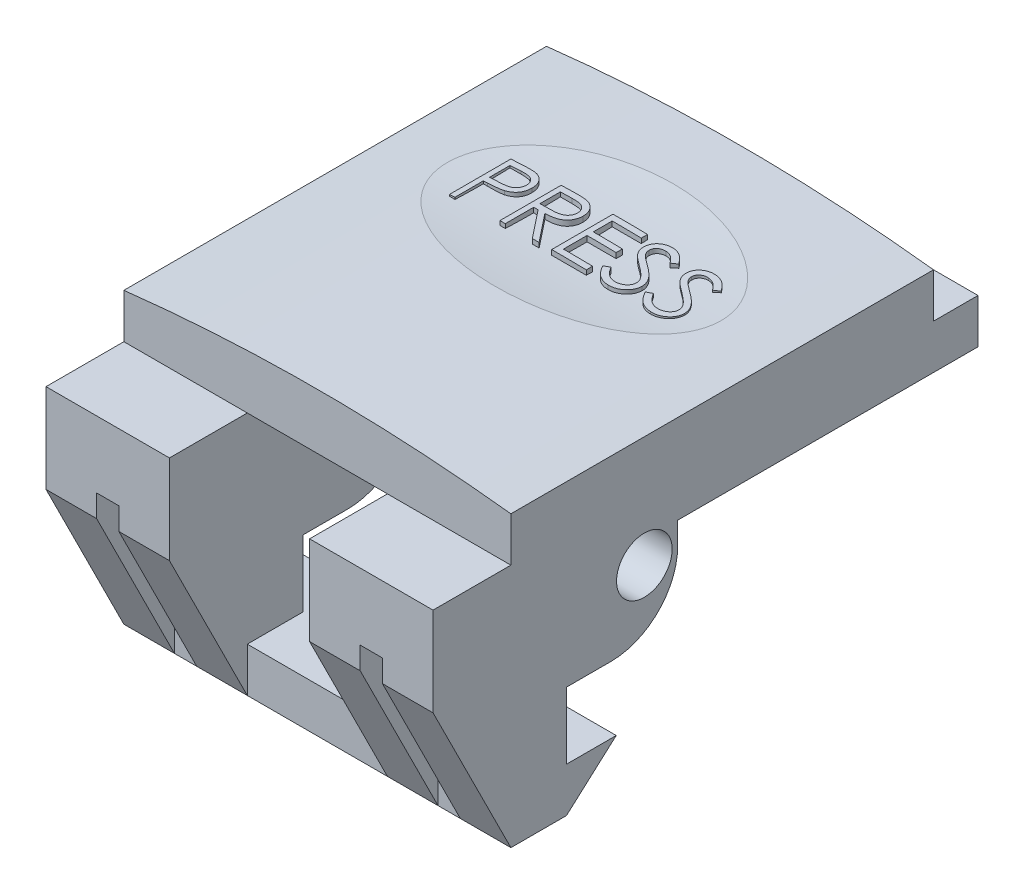
from build123d import *

# Parameters (mm, degrees)
SKETCH1_W                             = 22.098
SKETCH1_H                             = 24.13
BUTTON_MAIN_DEPTH                     = 2.54
LATCH_HOOK_REACH                      = 18.556
LATCH_HOOK_DIRECTION_2_REACH          = 18.556
SKETCH3_W                             = 8.001
SKETCH3_H                             = 11.43
CENTER_CUTOUT_DEPTH                   = 26.831000774
CENTER_CUTOUT_DEPTH_BACK              = 26.831000774
BACKSIDE_START                        = -4.445
SKETCH4_W                             = 1.27
SKETCH4_H                             = 10.16
SKETCH4_W_2                           = 8.001
SKETCH4_H_2                           = 2.54
BACKSIDE_CUTOUT_DEPTH                 = 4.445
SKETCH5_R                             = 1.5875
LATCH_AND_SPRING_PIN_HOLE_DEPTH       = 26.831000774
LATCH_AND_SPRING_PIN_HOLE_DEPTH_BACK  = 26.831000774
ROUNDED_TOP_SURFACE_REACH             = 27.831
ROUNDED_TOP_SURFACE_DIRECTION_2_REACH = 27.831
PRESS_LABEL_CUTOUT_DEPTH              = 8.255
PRESS_LABEL_REACH                     = 27.831
PRESS_LABEL_END_RADIUS                = 96.4438


with BuildPart() as part:
    # Sketch1 → button main (new body)
    with BuildSketch(Plane(origin=(0, 0, 0), x_dir=(1, 0, 0), z_dir=(0, 1, 0))):
        Rectangle(SKETCH1_W, SKETCH1_H)
    extrude(amount=-BUTTON_MAIN_DEPTH)

    # latch hook: up to this face of the body (flat: up to its plane)
    latch_hook_end = Plane(part.part.faces().sort_by_distance((11.049, -1.27, 0))[0])
    # Sketch2 → latch hook (add, up to the picked face)
    with BuildSketch(Plane(origin=(0, 0, 0), x_dir=(0, 0, -1), z_dir=(1, 0, 0)), mode=Mode.PRIVATE) as latch_hook_sk1:
        with BuildLine():
            Line((-12.065, -2.54), (14.605, -2.54))
            Line((14.605, -2.54), (14.605, -5.08))
            Line((14.605, -5.08), (-2.54, -5.08))
            Line((-2.54, -5.08), (-2.54, -6.35))
            ThreePointArc((-2.54, -6.35), (-3.655923164, -9.044076836), (-6.35, -10.16))
            Line((-6.35, -10.16), (-8.89, -10.16))
            Line((-8.89, -10.16), (-8.89, -13.97))
            Line((-8.89, -13.97), (-6.050193669, -13.97))
            Line((-6.050193669, -13.97), (-8.89, -16.51))
            Line((-8.89, -16.51), (-12.065, -16.51))
            Line((-12.065, -16.51), (-16.51, -7.62))
            Line((-16.51, -7.62), (-16.51, -2.54))
            Line((-16.51, -2.54), (-12.065, -2.54))
        make_face()
    latch_hook_tool1 = split(extrude(latch_hook_sk1.sketch, amount=LATCH_HOOK_REACH, mode=Mode.PRIVATE), bisect_by=latch_hook_end, keep=Keep.BOTH, mode=Mode.PRIVATE)
    add(latch_hook_tool1.solids().sort_by(Axis((0, -6.944553, 6.068075), (1, 0, 0)))[0])

    # latch hook direction 2: up to this face of the body (flat: up to its plane)
    latch_hook_direction_2_end = Plane(part.part.faces().sort_by_distance((-11.049, -1.27, 0))[0])
    # Sketch2 → latch hook direction 2 (add, up to the picked face)
    with BuildSketch(Plane(origin=(0, 0, 0), x_dir=(0, 0, -1), z_dir=(1, 0, 0)), mode=Mode.PRIVATE) as latch_hook_direction_2_sk1:
        with BuildLine():
            Line((-12.065, -2.54), (14.605, -2.54))
            Line((14.605, -2.54), (14.605, -5.08))
            Line((14.605, -5.08), (-2.54, -5.08))
            Line((-2.54, -5.08), (-2.54, -6.35))
            ThreePointArc((-2.54, -6.35), (-3.655923164, -9.044076836), (-6.35, -10.16))
            Line((-6.35, -10.16), (-8.89, -10.16))
            Line((-8.89, -10.16), (-8.89, -13.97))
            Line((-8.89, -13.97), (-6.050193669, -13.97))
            Line((-6.050193669, -13.97), (-8.89, -16.51))
            Line((-8.89, -16.51), (-12.065, -16.51))
            Line((-12.065, -16.51), (-16.51, -7.62))
            Line((-16.51, -7.62), (-16.51, -2.54))
            Line((-16.51, -2.54), (-12.065, -2.54))
        make_face()
    latch_hook_direction_2_tool1 = split(extrude(latch_hook_direction_2_sk1.sketch, amount=-LATCH_HOOK_DIRECTION_2_REACH, mode=Mode.PRIVATE), bisect_by=latch_hook_direction_2_end, keep=Keep.BOTH, mode=Mode.PRIVATE)
    add(latch_hook_direction_2_tool1.solids().sort_by(Axis((0, -6.944553, 6.068075), (-1, 0, 0)))[0])

    # Sketch3 → center cutout (cut, two sides)
    with BuildSketch(Plane.XY) as center_cutout_sk:
        with Locations((0, -8.255)):
            Rectangle(SKETCH3_W, SKETCH3_H)
    extrude(amount=CENTER_CUTOUT_DEPTH, mode=Mode.SUBTRACT)
    extrude(center_cutout_sk.sketch, amount=-CENTER_CUTOUT_DEPTH_BACK, mode=Mode.SUBTRACT)

    # Sketch4 → backside cutout (cut)
    with BuildSketch(Plane.XY.offset(16.51).offset(BACKSIDE_START)):
        with Locations((7.52475, -11.43)):
            Rectangle(SKETCH4_W, SKETCH4_H)
        with Locations((-7.52475, -11.43)):
            Rectangle(SKETCH4_W, SKETCH4_H)
        with Locations((0, -15.24)):
            Rectangle(SKETCH4_W_2, SKETCH4_H_2)
    extrude(amount=BACKSIDE_CUTOUT_DEPTH, mode=Mode.SUBTRACT)

    # Sketch5 → latch and spring pin hole (cut, two sides)
    with BuildSketch(Plane(origin=(0, 0, 0), x_dir=(0, 0, -1), z_dir=(1, 0, 0))) as latch_and_spring_pin_hole_sk:
        with Locations((-4.445, -6.35)):
            Circle(SKETCH5_R)
    extrude(amount=LATCH_AND_SPRING_PIN_HOLE_DEPTH, mode=Mode.SUBTRACT)
    extrude(latch_and_spring_pin_hole_sk.sketch, amount=-LATCH_AND_SPRING_PIN_HOLE_DEPTH_BACK, mode=Mode.SUBTRACT)

    # rounded top surface: up to this face of the body (flat: up to its plane)
    rounded_top_surface_end = Plane(part.part.faces().sort_by_distance((0, -1.27, 12.065))[0])
    # Sketch8 → rounded top surface (add, up to the picked face)
    with BuildSketch(Plane.XY, mode=Mode.PRIVATE) as rounded_top_surface_sk1:
        with BuildLine():
            Line((-11.049, 0), (11.049, 0))
            ThreePointArc((11.049, 0), (0, 0.635), (-11.049, 0))
        make_face()
    rounded_top_surface_tool1 = split(extrude(rounded_top_surface_sk1.sketch, amount=ROUNDED_TOP_SURFACE_REACH, mode=Mode.PRIVATE), bisect_by=rounded_top_surface_end, keep=Keep.BOTH, mode=Mode.PRIVATE)
    add(rounded_top_surface_tool1.solids().sort_by(Axis((0, 0.254072, 0), (0, 0, 1)))[0])

    # rounded top surface direction 2: up to this face of the body (flat: up to its plane)
    rounded_top_surface_direction_2_end = Plane(part.part.faces().sort_by_distance((0, -1.27, -12.065))[0])
    # Sketch8 → rounded top surface direction 2 (add, up to the picked face)
    with BuildSketch(Plane.XY, mode=Mode.PRIVATE) as rounded_top_surface_direction_2_sk1:
        with BuildLine():
            Line((-11.049, 0), (11.049, 0))
            ThreePointArc((11.049, 0), (0, 0.635), (-11.049, 0))
        make_face()
    rounded_top_surface_direction_2_tool1 = split(extrude(rounded_top_surface_direction_2_sk1.sketch, amount=-ROUNDED_TOP_SURFACE_DIRECTION_2_REACH, mode=Mode.PRIVATE), bisect_by=rounded_top_surface_direction_2_end, keep=Keep.BOTH, mode=Mode.PRIVATE)
    add(rounded_top_surface_direction_2_tool1.solids().sort_by(Axis((0, 0.254072, 0), (0, 0, -1)))[0])

    # Sketch11 → PRESS label cutout (cut, symmetric)
    with BuildSketch(Plane(origin=(0, 0, 0), x_dir=(0, 0, -1), z_dir=(1, 0, 0))):
        with BuildLine():
            Line((-1.905, 0.635), (8.255, 0.635))
            ThreePointArc((8.255, 0.635), (3.175, 0.3175), (-1.905, 0.635))
        make_face()
    extrude(amount=PRESS_LABEL_CUTOUT_DEPTH, both=True, mode=Mode.SUBTRACT)

    # PRESS label: up to this cylinder (the profile starts inside it)
    press_label_end = Plane(origin=(0, -95.8088, -4.1117645), z_dir=(0, 0, -1)) * Cylinder(PRESS_LABEL_END_RADIUS, 251.304077, mode=Mode.PRIVATE)
    # Sketch12 → PRESS label (add, up to the surface)
    with BuildSketch(Plane(origin=(0, 0, 0), x_dir=(1, 0, 0), z_dir=(0, 1, 0)), mode=Mode.PRIVATE) as press_label_sk1:
        with BuildLine():
            Line((-6.050444649, 5.030099377), (-5.364046412, 5.030099377))
            add(Edge.make_bspline(
                [(-5.364046412, 5.030099377), (-5.316835506, 5.030047481), (-5.226377313, 5.029948046), (-5.096662257, 5.0269333), (-4.978852526, 5.022906608), (-4.873202145, 5.017324715), (-4.779386047, 5.010728124), (-4.697828747, 5.001476085), (-4.627889191, 4.991815789), (-4.585982741, 4.981994383), (-4.566870931, 4.977515243)],
                knots=[0, 0, 0, 0, 1.415646017, 2.712440637, 3.8905458, 4.950247383, 5.884950622, 6.709939814, 7.411656543, 8, 8, 8, 8], degree=3))
            add(Edge.make_bspline(
                [(-4.566870931, 4.977515243), (-4.542677397, 4.970893293), (-4.49486042, 4.957805431), (-4.425959377, 4.931591708), (-4.360405531, 4.900509543), (-4.297973973, 4.865085603), (-4.23943189, 4.823800039), (-4.183905849, 4.778326421), (-4.131885869, 4.727614852), (-4.083664477, 4.672234112), (-4.039379679, 4.613113903), (-4.001249996, 4.549371673), (-3.969322769, 4.482080369), (-3.941939498, 4.411286798), (-3.922231044, 4.336396475), (-3.907384144, 4.257929762), (-3.897960516, 4.175895072), (-3.897057954, 4.119835204), (-3.896598495, 4.091297294)],
                knots=[0, 0, 0, 0, 0.999701418, 1.975846123, 2.934577507, 3.890451536, 4.834027766, 5.787354733, 6.749476667, 7.726910423, 8.712836071, 9.690891519, 10.682875813, 11.679750201, 12.712814741, 13.765529915, 14.8625177, 16, 16, 16, 16], degree=3))
            add(Edge.make_bspline(
                [(-3.896598495, 4.091297294), (-3.89701992, 4.062519517), (-3.897844466, 4.006213853), (-3.907740751, 3.923841065), (-3.921070943, 3.845122675), (-3.941567995, 3.770233225), (-3.968413668, 3.699617454), (-3.999905721, 3.632196222), (-4.037889251, 3.56911655), (-4.081534081, 3.510149433), (-4.130085676, 3.45523952), (-4.183338614, 3.404784726), (-4.241077906, 3.359080387), (-4.303120054, 3.318024044), (-4.370069903, 3.282567764), (-4.440912057, 3.250810459), (-4.516262273, 3.224139399), (-4.568404787, 3.210109337), (-4.594915803, 3.20297598)],
                knots=[0, 0, 0, 0, 1.121902311, 2.195077645, 3.232258892, 4.234102512, 5.217864754, 6.176164875, 7.132989551, 8.084763148, 9.034132444, 9.988522005, 10.94243251, 11.903244335, 12.886203696, 13.894208494, 14.929344452, 16, 16, 16, 16], degree=3))
            add(Edge.make_bspline(
                [(-4.594915803, 3.20297598), (-4.616843137, 3.198312999), (-4.664898164, 3.188093805), (-4.744040886, 3.176685348), (-4.836186272, 3.166947747), (-4.941208552, 3.15964661), (-5.059013457, 3.153396241), (-5.189664714, 3.148428147), (-5.333418792, 3.145698293), (-5.433690036, 3.145557501), (-5.486041604, 3.145483993)],
                knots=[0, 0, 0, 0, 0.601384939, 1.31797006, 2.144135048, 3.087295005, 4.142315834, 5.309527816, 6.595305764, 8, 8, 8, 8], degree=3))
            Line((-5.486041604, 3.145483993), (-5.736342085, 3.145483993))
            Line((-5.736342085, 3.145483993), (-5.736342085, 1.530099377))
            Line((-5.736342085, 1.530099377), (-6.050444649, 1.530099377))
            Line((-6.050444649, 1.530099377), (-6.050444649, 5.030099377))
        make_face()
        with BuildLine():
            Line((-5.736342085, 4.671125018), (-5.736342085, 3.504458352))
            Line((-5.736342085, 3.504458352), (-5.123561636, 3.496746012))
            add(Edge.make_bspline(
                [(-5.123561636, 3.496746012), (-5.09364171, 3.496730548), (-5.03588191, 3.496700696), (-4.952445687, 3.50068592), (-4.8750364, 3.505286452), (-4.803891825, 3.512022376), (-4.73897989, 3.521543633), (-4.680192361, 3.531155371), (-4.627985078, 3.545060734), (-4.566885877, 3.563783803), (-4.498802529, 3.595716419), (-4.424734981, 3.642066309), (-4.361964394, 3.701147017), (-4.307646097, 3.767574848), (-4.264540219, 3.841473978), (-4.232984227, 3.920542914), (-4.21444307, 4.003970764), (-4.211956876, 4.061058903), (-4.210701059, 4.08989505)],
                knots=[0, 0, 0, 0, 1.160613943, 2.240541288, 3.23993089, 4.169200891, 5.011653406, 5.7853311, 6.478053781, 7.106038997, 8.262395093, 9.384106736, 10.481365981, 11.59014053, 12.70357646, 13.786202915, 14.881775077, 16, 16, 16, 16], degree=3))
            add(Edge.make_bspline(
                [(-4.210701059, 4.08989505), (-4.211963706, 4.118033564), (-4.214473691, 4.173969446), (-4.233129554, 4.255948207), (-4.264478868, 4.334183911), (-4.307935462, 4.407156996), (-4.360676592, 4.4733458), (-4.421975935, 4.530842927), (-4.491689197, 4.57706463), (-4.556537428, 4.606897912), (-4.614138614, 4.625113187), (-4.664170574, 4.637858028), (-4.720661248, 4.648033634), (-4.783629028, 4.656273137), (-4.852585861, 4.663326598), (-4.928124176, 4.668112575), (-5.00995782, 4.670914031), (-5.06676839, 4.671052987), (-5.096217886, 4.671125018)],
                knots=[0, 0, 0, 0, 1.120700087, 2.227813068, 3.331159281, 4.466773991, 5.599788987, 6.693661531, 7.80175334, 8.91857717, 9.525282508, 10.207424825, 10.974604443, 11.810962634, 12.737642355, 13.736264703, 14.826523623, 16, 16, 16, 16], degree=3))
            Line((-5.096217886, 4.671125018), (-5.736342085, 4.671125018))
        make_face(mode=Mode.SUBTRACT)
    press_label_tool1 = extrude(press_label_sk1.sketch, amount=PRESS_LABEL_REACH, mode=Mode.PRIVATE) & press_label_end
    add(press_label_tool1.solids().sort_by_distance((-5.707246, 0, -4.989003))[0])
    # Sketch12 → PRESS label (add, up to the surface)
    with BuildSketch(Plane(origin=(0, 0, 0), x_dir=(1, 0, 0), z_dir=(0, 1, 0)), mode=Mode.PRIVATE) as press_label_sk2:
        with BuildLine():
            Line((-3.178649777, 5.030099377), (-2.478229104, 5.030099377))
            add(Edge.make_bspline(
                [(-2.478229104, 5.030099377), (-2.431487976, 5.029943791), (-2.341739831, 5.029645049), (-2.213166561, 5.027979286), (-2.096339464, 5.02320493), (-1.991319625, 5.019096347), (-1.89810897, 5.011604406), (-1.816421679, 5.004443759), (-1.746633981, 4.995070098), (-1.70438813, 4.986364675), (-1.685260354, 4.982423095)],
                knots=[0, 0, 0, 0, 1.410062039, 2.707475311, 3.878576406, 4.937260626, 5.877586885, 6.699081471, 7.410979367, 8, 8, 8, 8], degree=3))
            add(Edge.make_bspline(
                [(-1.685260354, 4.982423095), (-1.65965373, 4.97609633), (-1.608986741, 4.963577766), (-1.536036674, 4.937118165), (-1.466522351, 4.906498541), (-1.400732526, 4.870534821), (-1.338996735, 4.828960041), (-1.280678424, 4.782491918), (-1.225512961, 4.731384713), (-1.175731331, 4.674349871), (-1.128792279, 4.614513361), (-1.089203652, 4.549809605), (-1.055077173, 4.482148077), (-1.027906656, 4.410840659), (-1.006028682, 4.336578888), (-0.990602443, 4.258690091), (-0.981351255, 4.177529116), (-0.9804094, 4.122171207), (-0.979931828, 4.094101781)],
                knots=[0, 0, 0, 0, 1.027469482, 2.033020251, 3.019912614, 3.986113645, 4.951240523, 5.91722682, 6.890402269, 7.87763091, 8.8651537, 9.85103654, 10.82876324, 11.815024772, 12.821070561, 13.842952187, 14.906261191, 16, 16, 16, 16], degree=3))
            add(Edge.make_bspline(
                [(-0.979931828, 4.094101781), (-0.981400827, 4.047466677), (-0.984267222, 3.956469509), (-1.010992326, 3.824408627), (-1.054768846, 3.701219313), (-1.115092135, 3.587056675), (-1.191911611, 3.484146029), (-1.284236402, 3.393755574), (-1.392118013, 3.318115662), (-1.492547329, 3.265662857), (-1.581261529, 3.232069948), (-1.654294842, 3.208433589), (-1.733961819, 3.190171624), (-1.819499154, 3.173811492), (-1.911262809, 3.161459798), (-2.009032849, 3.152413203), (-2.112879, 3.146759155), (-2.184218069, 3.14591715), (-2.220917405, 3.145483993)],
                knots=[0, 0, 0, 0, 1.260483769, 2.459530307, 3.627416485, 4.787058657, 5.939039949, 7.08810263, 8.267026773, 9.491475466, 10.141966685, 10.831826277, 11.566392101, 12.351337768, 13.187381173, 14.07005841, 15.007169909, 16, 16, 16, 16], degree=3))
            Line((-2.220917405, 3.145483993), (-0.935060034, 1.530099377))
            Line((-0.935060034, 1.530099377), (-1.323481508, 1.530099377))
            Line((-1.323481508, 1.530099377), (-2.60933888, 3.145483993))
            Line((-2.60933888, 3.145483993), (-2.864547213, 3.145483993))
            Line((-2.864547213, 3.145483993), (-2.864547213, 1.530099377))
            Line((-2.864547213, 1.530099377), (-3.178649777, 1.530099377))
            Line((-3.178649777, 1.530099377), (-3.178649777, 5.030099377))
        make_face()
        with BuildLine():
            Line((-2.864547213, 4.671125018), (-2.864547213, 3.504458352))
            Line((-2.864547213, 3.504458352), (-2.223721893, 3.499550499))
            add(Edge.make_bspline(
                [(-2.223721893, 3.499550499), (-2.193801854, 3.499537263), (-2.135808297, 3.499511606), (-2.051907632, 3.503505382), (-1.97378752, 3.508048701), (-1.901746768, 3.514998046), (-1.835753193, 3.523954118), (-1.775839779, 3.535157102), (-1.721908727, 3.548209165), (-1.659010189, 3.568410791), (-1.588773658, 3.600416809), (-1.512442198, 3.646982308), (-1.44743986, 3.705551427), (-1.392521998, 3.772524883), (-1.348392566, 3.846161132), (-1.317280512, 3.925577501), (-1.29753807, 4.008769099), (-1.295209524, 4.065947207), (-1.294034393, 4.094802903)],
                knots=[0, 0, 0, 0, 1.146690395, 2.22261258, 3.21895312, 4.145990853, 4.996080663, 5.770904154, 6.481378293, 7.121626537, 8.300444488, 9.431385265, 10.535395872, 11.636531494, 12.74115979, 13.810798291, 14.895190096, 16, 16, 16, 16], degree=3))
            add(Edge.make_bspline(
                [(-1.294034393, 4.094802903), (-1.295236514, 4.122949477), (-1.297618679, 4.178725715), (-1.317067448, 4.260381626), (-1.349956829, 4.337448576), (-1.394279067, 4.409613061), (-1.448278222, 4.475118797), (-1.511596034, 4.53116595), (-1.58250123, 4.577415414), (-1.648772428, 4.606969795), (-1.70800664, 4.625089648), (-1.759436301, 4.637840812), (-1.817547778, 4.648085281), (-1.882623237, 4.656293342), (-1.954384868, 4.663348286), (-2.033195519, 4.668100065), (-2.118532299, 4.670913929), (-2.17767923, 4.671053018), (-2.208297213, 4.671125018)],
                knots=[0, 0, 0, 0, 1.101028733, 2.181837193, 3.264309656, 4.369019818, 5.486613113, 6.575447106, 7.666700264, 8.788928104, 9.402425223, 10.0903467, 10.862060571, 11.710948788, 12.657782767, 13.684531032, 14.801375019, 16, 16, 16, 16], degree=3))
            Line((-2.208297213, 4.671125018), (-2.864547213, 4.671125018))
        make_face(mode=Mode.SUBTRACT)
    press_label_tool2 = extrude(press_label_sk2.sketch, amount=PRESS_LABEL_REACH, mode=Mode.PRIVATE) & press_label_end
    add(press_label_tool2.solids().sort_by_distance((-2.241662, 0, -3.471064))[0])
    # Sketch12 → PRESS label (add, up to the surface)
    with BuildSketch(Plane(origin=(0, 0, 0), x_dir=(1, 0, 0), z_dir=(0, 1, 0)), mode=Mode.PRIVATE) as press_label_sk3:
        Polygon((-0.217111316, 5.030099377), (1.757247659, 5.030099377), (1.757247659, 4.671125018), (0.096991248, 4.671125018), (0.096991248, 3.594201941), (1.757247659, 3.594201941), (1.757247659, 3.235227583), (0.096991248, 3.235227583), (0.096991248, 1.889073736), (1.757247659, 1.889073736), (1.757247659, 1.530099377), (-0.217111316, 1.530099377), align=None)
    press_label_tool3 = extrude(press_label_sk3.sketch, amount=PRESS_LABEL_REACH, mode=Mode.PRIVATE) & press_label_end
    add(press_label_tool3.solids().sort_by_distance((0.551248, 0, -3.307886))[0])
    # Sketch12 → PRESS label (add, up to the surface)
    with BuildSketch(Plane(origin=(0, 0, 0), x_dir=(1, 0, 0), z_dir=(0, 1, 0)), mode=Mode.PRIVATE) as press_label_sk4:
        with BuildLine():
            Line((2.026478428, 2.205279666), (2.322351825, 2.38266348))
            add(Edge.make_bspline(
                [(2.322351825, 2.38266348), (2.349870063, 2.336599095), (2.402593943, 2.248341511), (2.490545302, 2.129083471), (2.581678214, 2.027721314), (2.676667547, 1.944844706), (2.774933495, 1.87959582), (2.877117549, 1.833393588), (2.98287536, 1.804577613), (3.054849181, 1.801077526), (3.090781313, 1.799330147)],
                knots=[0, 0, 0, 0, 1.272034388, 2.437168799, 3.508375237, 4.49857839, 5.41946034, 6.295179144, 7.148887113, 8, 8, 8, 8], degree=3))
            add(Edge.make_bspline(
                [(3.090781313, 1.799330147), (3.121468173, 1.800184819), (3.182304946, 1.801879209), (3.271867189, 1.818160011), (3.358848991, 1.84317214), (3.441457629, 1.878993072), (3.518553244, 1.922331558), (3.586159939, 1.974677735), (3.644606052, 2.033283941), (3.692415167, 2.098666595), (3.729095202, 2.168983744), (3.75728727, 2.241159695), (3.772932344, 2.316328264), (3.775289097, 2.366938727), (3.776478428, 2.392479185)],
                knots=[0, 0, 0, 0, 1.095163259, 2.171163733, 3.241058638, 4.321873601, 5.38011039, 6.391990106, 7.366004449, 8.327778327, 9.272591725, 10.192022065, 11.087607919, 12, 12, 12, 12], degree=3))
            add(Edge.make_bspline(
                [(3.776478428, 2.392479185), (3.775004117, 2.421620035), (3.772007059, 2.480859124), (3.746675579, 2.568258777), (3.706826332, 2.654751347), (3.670063688, 2.708252612), (3.650977627, 2.736028865)],
                knots=[0, 0, 0, 0, 0.938893495, 1.908633276, 2.914225137, 4, 4, 4, 4], degree=3))
            add(Edge.make_bspline(
                [(3.650977627, 2.736028865), (3.635307012, 2.756075688), (3.602408518, 2.798161487), (3.545851006, 2.860806722), (3.479484891, 2.925425141), (3.405581336, 2.994484198), (3.321448248, 3.064771995), (3.229720733, 3.139640273), (3.128056874, 3.21624185), (3.056757378, 3.267614415), (3.019968011, 3.294121813)],
                knots=[0, 0, 0, 0, 0.722233717, 1.516239348, 2.393582979, 3.351407094, 4.387010283, 5.505090956, 6.712668013, 8, 8, 8, 8], degree=3))
            add(Edge.make_bspline(
                [(3.019968011, 3.294121813), (2.983144015, 3.320350401), (2.912739338, 3.370497463), (2.814280756, 3.444921747), (2.726236293, 3.512965617), (2.648997277, 3.575269629), (2.58259768, 3.631842234), (2.526514269, 3.682140173), (2.482175712, 3.727523734), (2.457520131, 3.756965075), (2.446450383, 3.770183512)],
                knots=[0, 0, 0, 0, 1.452282411, 2.77665338, 3.964542531, 5.026858415, 5.96415736, 6.766646006, 7.446254459, 8, 8, 8, 8], degree=3))
            add(Edge.make_bspline(
                [(2.446450383, 3.770183512), (2.430977838, 3.790784549), (2.400549001, 3.831299253), (2.360382996, 3.89462411), (2.326243833, 3.959447376), (2.299481501, 4.02594324), (2.276945282, 4.093178169), (2.261787351, 4.162029415), (2.252295954, 4.232188033), (2.251323968, 4.279401534), (2.250837402, 4.303036076)],
                knots=[0, 0, 0, 0, 1.068054152, 2.10047183, 3.106115577, 4.101338837, 5.06977816, 6.043150881, 7.020423561, 8, 8, 8, 8], degree=3))
            add(Edge.make_bspline(
                [(2.250837402, 4.303036076), (2.252142611, 4.340065851), (2.254725131, 4.413333914), (2.276565649, 4.520364745), (2.311038542, 4.622551162), (2.35933343, 4.718881496), (2.421590783, 4.806847477), (2.493636757, 4.887460964), (2.579448244, 4.955229546), (2.673600867, 5.014441604), (2.776657239, 5.060787529), (2.884648142, 5.09574851), (2.997745214, 5.115557767), (3.074348349, 5.118400532), (3.11321721, 5.119842967)],
                knots=[0, 0, 0, 0, 1.005424448, 1.989358655, 2.955360095, 3.929531133, 4.905563448, 5.876582895, 6.856512386, 7.866279853, 8.892233794, 9.918561126, 10.94386622, 12, 12, 12, 12], degree=3))
            add(Edge.make_bspline(
                [(3.11321721, 5.119842967), (3.15446131, 5.118420416), (3.236482662, 5.115591414), (3.357131878, 5.090993883), (3.473292594, 5.050293211), (3.566735859, 5.004104553), (3.63986862, 4.957973138), (3.695641353, 4.915953313), (3.752158804, 4.867578205), (3.809876859, 4.812718959), (3.867817518, 4.750872208), (3.92684097, 4.682461519), (3.987085239, 4.607904963), (4.025841099, 4.554680462), (4.045709197, 4.52739505)],
                knots=[0, 0, 0, 0, 1.286793592, 2.559021753, 3.825965368, 5.121522368, 5.803751409, 6.523245864, 7.299691795, 8.125521123, 9.008227632, 9.944561021, 10.946284179, 12, 12, 12, 12], degree=3))
            Line((4.045709197, 4.52739505), (3.76175487, 4.312150659))
            add(Edge.make_bspline(
                [(3.76175487, 4.312150659), (3.744608938, 4.33423935), (3.711589881, 4.376777003), (3.661460394, 4.436348319), (3.614211746, 4.490764798), (3.567661346, 4.538029926), (3.524267715, 4.58073206), (3.482150672, 4.617291816), (3.441916321, 4.648067412), (3.391199411, 4.680910972), (3.327481692, 4.713467475), (3.247497156, 4.741016553), (3.163910881, 4.757571615), (3.106981249, 4.759760503), (3.07816112, 4.760868608)],
                knots=[0, 0, 0, 0, 1.181633172, 2.275549214, 3.290209073, 4.226197932, 5.078386478, 5.862611352, 6.581680152, 7.217281963, 8.414376989, 9.595101626, 10.782541182, 12, 12, 12, 12], degree=3))
            add(Edge.make_bspline(
                [(3.07816112, 4.760868608), (3.042004598, 4.759656908), (2.97228015, 4.757320259), (2.873289914, 4.731800274), (2.784195989, 4.691618413), (2.707643424, 4.635303435), (2.643906447, 4.568582443), (2.597800988, 4.491803588), (2.570050824, 4.407021185), (2.566664544, 4.347879529), (2.564939966, 4.317759634)],
                knots=[0, 0, 0, 0, 1.14458467, 2.207223713, 3.21896685, 4.227309161, 5.202851033, 6.127160689, 7.046193047, 8, 8, 8, 8], degree=3))
            add(Edge.make_bspline(
                [(2.564939966, 4.317759634), (2.565333093, 4.299008155), (2.566119989, 4.261474536), (2.577094787, 4.206023114), (2.591194116, 4.150711774), (2.613536748, 4.095789192), (2.644382051, 4.040294833), (2.684887227, 3.983273095), (2.735900539, 3.924221386), (2.774977551, 3.885814013), (2.795609037, 3.865536076)],
                knots=[0, 0, 0, 0, 0.858281714, 1.717966888, 2.583508476, 3.4729293, 4.427298488, 5.488583878, 6.674047936, 8, 8, 8, 8], degree=3))
            add(Edge.make_bspline(
                [(2.795609037, 3.865536076), (2.803270409, 3.85869905), (2.821472076, 3.842455842), (2.854748002, 3.815863561), (2.8986908, 3.783060789), (2.952153002, 3.742473473), (3.016120363, 3.69539201), (3.090599919, 3.642418398), (3.174761452, 3.581832939), (3.234483368, 3.539475399), (3.266061761, 3.517078544)],
                knots=[0, 0, 0, 0, 0.420754252, 0.999615792, 1.744751191, 2.668019286, 3.750313428, 4.999500688, 6.413464383, 8, 8, 8, 8], degree=3))
            add(Edge.make_bspline(
                [(3.266061761, 3.517078544), (3.304047675, 3.489437185), (3.377602131, 3.435913523), (3.482259711, 3.355497843), (3.577153519, 3.276850074), (3.662616723, 3.200472467), (3.739493631, 3.126944374), (3.806931352, 3.055381194), (3.865617032, 2.986295621), (3.92879625, 2.897723045), (3.99335407, 2.788941961), (4.048795577, 2.655663723), (4.083753925, 2.521867402), (4.08832544, 2.431940566), (4.090580992, 2.387571333)],
                knots=[0, 0, 0, 0, 1.163667725, 2.253281268, 3.268753668, 4.215851969, 5.092017293, 5.902905408, 6.650798638, 7.335211899, 8.59617414, 9.77448103, 10.901945474, 12, 12, 12, 12], degree=3))
            add(Edge.make_bspline(
                [(4.090580992, 2.387571333), (4.089923854, 2.356192967), (4.088622339, 2.294045584), (4.073661425, 2.202790507), (4.05174176, 2.114159637), (4.018704526, 2.029248525), (3.978381368, 1.946503762), (3.92721512, 1.868095862), (3.867907435, 1.792289463), (3.79987367, 1.721105972), (3.725427768, 1.655759776), (3.646744073, 1.597630714), (3.5636938, 1.549162391), (3.476727484, 1.509611549), (3.385825147, 1.478678031), (3.291017363, 1.456265162), (3.192147852, 1.442509451), (3.12494737, 1.44108169), (3.090781313, 1.440355788)],
                knots=[0, 0, 0, 0, 0.983748083, 1.948392443, 2.894712957, 3.844097841, 4.80183111, 5.778335162, 6.776009319, 7.81870978, 8.863265674, 9.881300176, 10.883814829, 11.87499822, 12.874611388, 13.892143829, 14.928324115, 16, 16, 16, 16], degree=3))
            add(Edge.make_bspline(
                [(3.090781313, 1.440355788), (3.06434597, 1.440866969), (3.01180821, 1.441882895), (2.934098728, 1.450864175), (2.857959138, 1.463571279), (2.784344856, 1.483745349), (2.712307445, 1.508222326), (2.64216021, 1.538360658), (2.573869156, 1.57447786), (2.507051574, 1.615772884), (2.441877399, 1.663830629), (2.378957931, 1.719804125), (2.316228745, 1.78214963), (2.255541349, 1.852560194), (2.195668205, 1.929898277), (2.137789795, 2.01488746), (2.080708078, 2.107064814), (2.04489261, 2.171929899), (2.026478428, 2.205279666)],
                knots=[0, 0, 0, 0, 0.915332311, 1.819136955, 2.706846663, 3.586547465, 4.459518054, 5.340707479, 6.227863349, 7.133153174, 8.059268498, 9.028702269, 10.047606654, 11.120612155, 12.245963614, 13.433783089, 14.680604001, 16, 16, 16, 16], degree=3))
        make_face()
    press_label_tool4 = extrude(press_label_sk4.sketch, amount=PRESS_LABEL_REACH, mode=Mode.PRIVATE) & press_label_end
    add(press_label_tool4.solids().sort_by_distance((3.128511, 0, -3.234526))[0])
    # Sketch12 → PRESS label (add, up to the surface)
    with BuildSketch(Plane(origin=(0, 0, 0), x_dir=(1, 0, 0), z_dir=(0, 1, 0)), mode=Mode.PRIVATE) as press_label_sk5:
        with BuildLine():
            Line((4.449555351, 2.205279666), (4.745428748, 2.38266348))
            add(Edge.make_bspline(
                [(4.745428748, 2.38266348), (4.772946986, 2.336599095), (4.825670866, 2.248341511), (4.913622225, 2.129083471), (5.004755137, 2.027721314), (5.09974447, 1.944844706), (5.198010418, 1.87959582), (5.300194472, 1.833393588), (5.405952283, 1.804577613), (5.477926104, 1.801077526), (5.513858236, 1.799330147)],
                knots=[0, 0, 0, 0, 1.272034388, 2.437168799, 3.508375237, 4.49857839, 5.41946034, 6.295179144, 7.148887113, 8, 8, 8, 8], degree=3))
            add(Edge.make_bspline(
                [(5.513858236, 1.799330147), (5.544545096, 1.800184819), (5.605381869, 1.801879209), (5.694944112, 1.818160011), (5.781925914, 1.84317214), (5.864534552, 1.878993072), (5.941630167, 1.922331558), (6.009236862, 1.974677735), (6.067682975, 2.033283941), (6.11549209, 2.098666595), (6.152172125, 2.168983744), (6.180364193, 2.241159695), (6.196009267, 2.316328264), (6.198366021, 2.366938727), (6.199555351, 2.392479185)],
                knots=[0, 0, 0, 0, 1.095163259, 2.171163733, 3.241058638, 4.321873601, 5.38011039, 6.391990106, 7.366004449, 8.327778327, 9.272591725, 10.192022065, 11.087607919, 12, 12, 12, 12], degree=3))
            add(Edge.make_bspline(
                [(6.199555351, 2.392479185), (6.19808104, 2.421620035), (6.195083982, 2.480859124), (6.169752502, 2.568258777), (6.129903255, 2.654751347), (6.093140611, 2.708252612), (6.07405455, 2.736028865)],
                knots=[0, 0, 0, 0, 0.938893495, 1.908633276, 2.914225137, 4, 4, 4, 4], degree=3))
            add(Edge.make_bspline(
                [(6.07405455, 2.736028865), (6.058383936, 2.756075688), (6.025485441, 2.798161487), (5.968927929, 2.860806722), (5.902561814, 2.925425141), (5.828658259, 2.994484198), (5.744525171, 3.064771995), (5.652797656, 3.139640273), (5.551133797, 3.21624185), (5.479834301, 3.267614415), (5.443044934, 3.294121813)],
                knots=[0, 0, 0, 0, 0.722233717, 1.516239348, 2.393582979, 3.351407094, 4.387010283, 5.505090956, 6.712668013, 8, 8, 8, 8], degree=3))
            add(Edge.make_bspline(
                [(5.443044934, 3.294121813), (5.406220938, 3.320350401), (5.335816262, 3.370497463), (5.237357679, 3.444921747), (5.149313216, 3.512965617), (5.0720742, 3.575269629), (5.005674603, 3.631842234), (4.949591192, 3.682140173), (4.905252635, 3.727523734), (4.880597054, 3.756965075), (4.869527306, 3.770183512)],
                knots=[0, 0, 0, 0, 1.452282411, 2.77665338, 3.964542531, 5.026858415, 5.96415736, 6.766646006, 7.446254459, 8, 8, 8, 8], degree=3))
            add(Edge.make_bspline(
                [(4.869527306, 3.770183512), (4.854054761, 3.790784549), (4.823625924, 3.831299253), (4.783459919, 3.89462411), (4.749320756, 3.959447376), (4.722558424, 4.02594324), (4.700022205, 4.093178169), (4.684864274, 4.162029415), (4.675372877, 4.232188033), (4.674400891, 4.279401534), (4.673914325, 4.303036076)],
                knots=[0, 0, 0, 0, 1.068054152, 2.10047183, 3.106115577, 4.101338837, 5.06977816, 6.043150881, 7.020423561, 8, 8, 8, 8], degree=3))
            add(Edge.make_bspline(
                [(4.673914325, 4.303036076), (4.675219534, 4.340065851), (4.677802054, 4.413333914), (4.699642572, 4.520364745), (4.734115465, 4.622551162), (4.782410353, 4.718881496), (4.844667706, 4.806847477), (4.91671368, 4.887460964), (5.002525167, 4.955229546), (5.09667779, 5.014441604), (5.199734162, 5.060787529), (5.307725065, 5.09574851), (5.420822137, 5.115557767), (5.497425272, 5.118400532), (5.536294133, 5.119842967)],
                knots=[0, 0, 0, 0, 1.005424448, 1.989358655, 2.955360095, 3.929531133, 4.905563448, 5.876582895, 6.856512386, 7.866279853, 8.892233794, 9.918561126, 10.94386622, 12, 12, 12, 12], degree=3))
            add(Edge.make_bspline(
                [(5.536294133, 5.119842967), (5.577538233, 5.118420416), (5.659559585, 5.115591414), (5.780208801, 5.090993883), (5.896369517, 5.050293211), (5.989812782, 5.004104553), (6.062945543, 4.957973138), (6.118718276, 4.915953313), (6.175235727, 4.867578205), (6.232953782, 4.812718959), (6.290894441, 4.750872208), (6.349917893, 4.682461519), (6.410162162, 4.607904963), (6.448918022, 4.554680462), (6.46878612, 4.52739505)],
                knots=[0, 0, 0, 0, 1.286793592, 2.559021753, 3.825965368, 5.121522368, 5.803751409, 6.523245864, 7.299691795, 8.125521123, 9.008227632, 9.944561021, 10.946284179, 12, 12, 12, 12], degree=3))
            Line((6.46878612, 4.52739505), (6.184831793, 4.312150659))
            add(Edge.make_bspline(
                [(6.184831793, 4.312150659), (6.167685861, 4.33423935), (6.134666804, 4.376777003), (6.084537317, 4.436348319), (6.037288669, 4.490764798), (5.990738269, 4.538029926), (5.947344638, 4.58073206), (5.905227595, 4.617291816), (5.864993244, 4.648067412), (5.814276334, 4.680910972), (5.750558615, 4.713467475), (5.670574079, 4.741016553), (5.586987804, 4.757571615), (5.530058173, 4.759760503), (5.501238043, 4.760868608)],
                knots=[0, 0, 0, 0, 1.181633172, 2.275549214, 3.290209073, 4.226197932, 5.078386478, 5.862611352, 6.581680152, 7.217281963, 8.414376989, 9.595101626, 10.782541182, 12, 12, 12, 12], degree=3))
            add(Edge.make_bspline(
                [(5.501238043, 4.760868608), (5.465081521, 4.759656908), (5.395357073, 4.757320259), (5.296366837, 4.731800274), (5.207272912, 4.691618413), (5.130720347, 4.635303435), (5.06698337, 4.568582443), (5.020877911, 4.491803588), (4.993127747, 4.407021185), (4.989741467, 4.347879529), (4.988016889, 4.317759634)],
                knots=[0, 0, 0, 0, 1.14458467, 2.207223713, 3.21896685, 4.227309161, 5.202851033, 6.127160689, 7.046193047, 8, 8, 8, 8], degree=3))
            add(Edge.make_bspline(
                [(4.988016889, 4.317759634), (4.988410016, 4.299008155), (4.989196912, 4.261474536), (5.00017171, 4.206023114), (5.014271039, 4.150711774), (5.036613671, 4.095789192), (5.067458974, 4.040294833), (5.10796415, 3.983273095), (5.158977462, 3.924221386), (5.198054475, 3.885814013), (5.21868596, 3.865536076)],
                knots=[0, 0, 0, 0, 0.858281714, 1.717966888, 2.583508476, 3.4729293, 4.427298488, 5.488583878, 6.674047936, 8, 8, 8, 8], degree=3))
            add(Edge.make_bspline(
                [(5.21868596, 3.865536076), (5.226347332, 3.85869905), (5.244549, 3.842455842), (5.277824925, 3.815863561), (5.321767723, 3.783060789), (5.375229925, 3.742473473), (5.439197286, 3.69539201), (5.513676843, 3.642418398), (5.597838375, 3.581832939), (5.657560291, 3.539475399), (5.689138684, 3.517078544)],
                knots=[0, 0, 0, 0, 0.420754252, 0.999615792, 1.744751191, 2.668019286, 3.750313428, 4.999500688, 6.413464383, 8, 8, 8, 8], degree=3))
            add(Edge.make_bspline(
                [(5.689138684, 3.517078544), (5.727124598, 3.489437185), (5.800679054, 3.435913523), (5.905336634, 3.355497843), (6.000230442, 3.276850074), (6.085693646, 3.200472467), (6.162570554, 3.126944374), (6.230008275, 3.055381194), (6.288693955, 2.986295621), (6.351873174, 2.897723045), (6.416430993, 2.788941961), (6.4718725, 2.655663723), (6.506830848, 2.521867402), (6.511402363, 2.431940566), (6.513657915, 2.387571333)],
                knots=[0, 0, 0, 0, 1.163667725, 2.253281268, 3.268753668, 4.215851969, 5.092017293, 5.902905408, 6.650798638, 7.335211899, 8.59617414, 9.77448103, 10.901945474, 12, 12, 12, 12], degree=3))
            add(Edge.make_bspline(
                [(6.513657915, 2.387571333), (6.513000777, 2.356192967), (6.511699262, 2.294045584), (6.496738348, 2.202790507), (6.474818683, 2.114159637), (6.441781449, 2.029248525), (6.401458291, 1.946503762), (6.350292043, 1.868095862), (6.290984358, 1.792289463), (6.222950593, 1.721105972), (6.148504691, 1.655759776), (6.069820996, 1.597630714), (5.986770723, 1.549162391), (5.899804407, 1.509611549), (5.80890207, 1.478678031), (5.714094286, 1.456265162), (5.615224775, 1.442509451), (5.548024293, 1.44108169), (5.513858236, 1.440355788)],
                knots=[0, 0, 0, 0, 0.983748083, 1.948392443, 2.894712957, 3.844097841, 4.80183111, 5.778335162, 6.776009319, 7.81870978, 8.863265674, 9.881300176, 10.883814829, 11.87499822, 12.874611388, 13.892143829, 14.928324115, 16, 16, 16, 16], degree=3))
            add(Edge.make_bspline(
                [(5.513858236, 1.440355788), (5.487422893, 1.440866969), (5.434885133, 1.441882895), (5.357175651, 1.450864175), (5.281036062, 1.463571279), (5.207421779, 1.483745349), (5.135384368, 1.508222326), (5.065237133, 1.538360658), (4.996946079, 1.57447786), (4.930128497, 1.615772884), (4.864954322, 1.663830629), (4.802034854, 1.719804125), (4.739305669, 1.78214963), (4.678618272, 1.852560194), (4.618745128, 1.929898277), (4.560866718, 2.01488746), (4.503785001, 2.107064814), (4.467969533, 2.171929899), (4.449555351, 2.205279666)],
                knots=[0, 0, 0, 0, 0.915332311, 1.819136955, 2.706846663, 3.586547465, 4.459518054, 5.340707479, 6.227863349, 7.133153174, 8.059268498, 9.028702269, 10.047606654, 11.120612155, 12.245963614, 13.433783089, 14.680604001, 16, 16, 16, 16], degree=3))
        make_face()
    press_label_tool5 = extrude(press_label_sk5.sketch, amount=PRESS_LABEL_REACH, mode=Mode.PRIVATE) & press_label_end
    add(press_label_tool5.solids().sort_by_distance((5.551588, 0, -3.234526))[0])


solid = part.part
